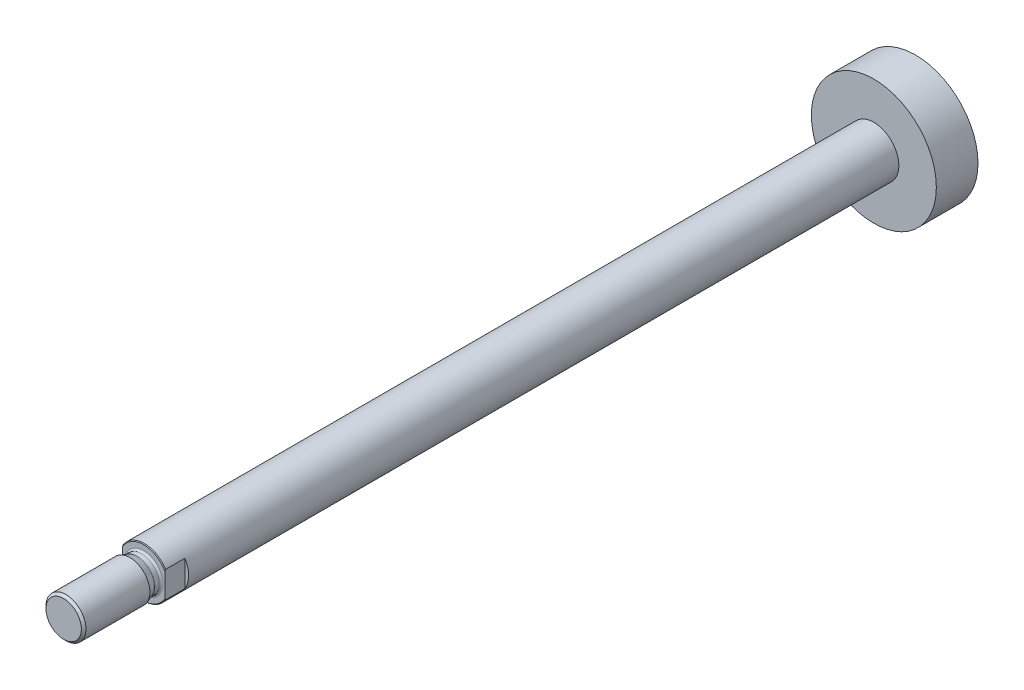
from build123d import *

# Parameters (mm, degrees)
CUT_EXTRUDE1_DEPTH      = 17
CUT_EXTRUDE1_DEPTH_BACK = 17


with BuildPart() as part:
    # Sketch1 → Revolve1 (revolve)
    with BuildSketch(Plane(origin=(0, 0, 0), x_dir=(0, 0, -1), z_dir=(1, 0, 0))):
        Polygon((-35.8, 0), (-35.8, 9.717157288), (-35.517157288, 10), (256.333333333, 10), (256.333333333, 25), (273, 25), (273, 0), align=None)
    revolve(axis=Axis((0, 0, -273), (0, 0, 1)))

    # Sketch2 → Cut-Extrude1 (cut, two sides: drawn at the far end of the back side and taken through both)
    with BuildSketch(Plane(origin=(0, 0, 0), x_dir=(1, 0, 0), z_dir=(0, 1, 0)).offset(-CUT_EXTRUDE1_DEPTH_BACK)):
        Polygon((-17, -61.8), (17, -61.8), (17, -27.8), (8.5, -27.8), (8.5, -43.8), (-8.5, -43.8), (-8.5, -27.8), (-17, -27.8), align=None)
    extrude(amount=CUT_EXTRUDE1_DEPTH + CUT_EXTRUDE1_DEPTH_BACK, mode=Mode.SUBTRACT)

    # Sketch3 → Revolve2 (revolve)
    with BuildSketch(Plane(origin=(0, 0, 0), x_dir=(0, 0, -1), z_dir=(1, 0, 0))):
        with BuildLine():
            Line((-67.8, 0), (-67.8, 7.08))
            Line((-67.8, 7.08), (-66.88, 8))
            Line((-66.88, 8), (-41.28485129, 8))
            Line((-41.28485129, 8), (-38.524269872, 6.995230534))
            ThreePointArc((-38.524269872, 6.995230534), (-38.397990898, 6.961394185), (-38.267754764, 6.95))
            Line((-38.267754764, 6.95), (-36.55, 6.95))
            ThreePointArc((-36.55, 6.95), (-36.019669914, 7.169669914), (-35.8, 7.7))
            Line((-35.8, 7.7), (-35.05, 7.7))
            Line((-35.05, 7.7), (-35.05, 0))
            Line((-35.05, 0), (-67.8, 0))
        make_face()
    revolve(axis=Axis((0, 0, 35.05), (0, 0, 1)))


solid = part.part
